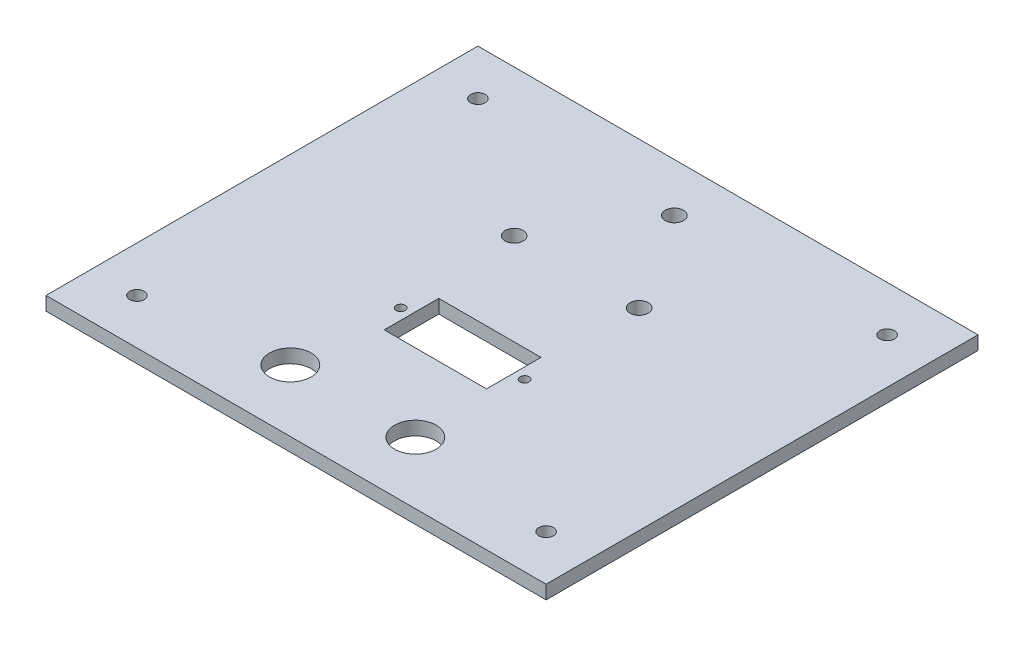
from build123d import *

# Parameters (mm, degrees)
SKETCH1_W           = 110
SKETCH1_H           = 95
SKETCH1_R           = 2
BOSS_EXTRUDE1_DEPTH = 3
SKETCH2_R           = 1.6
CUT_EXTRUDE1_DEPTH  = 3
SKETCH4_R           = 4.575
CUT_EXTRUDE3_DEPTH  = 3
SKETCH5_R           = 1
SKETCH5_W           = 22.5
SKETCH5_H           = 12
CUT_EXTRUDE4_DEPTH  = 10


with BuildPart() as part:
    # Sketch1 → Boss-Extrude1 (new body)
    with BuildSketch(Plane(origin=(0, 0, 0), x_dir=(1, 0, 0), z_dir=(0, 1, 0))):
        Rectangle(SKETCH1_W, SKETCH1_H)
        with Locations((-1.134990048, 36.85560657)):
            Circle(SKETCH1_R, mode=Mode.SUBTRACT)
        with Locations((-14.884990048, 15.35560657)):
            Circle(SKETCH1_R, mode=Mode.SUBTRACT)
        with Locations((12.615009952, 15.35560657)):
            Circle(SKETCH1_R, mode=Mode.SUBTRACT)
    extrude(amount=BOSS_EXTRUDE1_DEPTH)

    # Sketch2 → Cut-Extrude1 (cut)
    with BuildSketch(Plane(origin=(0, 3, 0), x_dir=(1, 0, 0), z_dir=(0, 1, 0))):
        with Locations((-45, 37.5)):
            Circle(SKETCH2_R)
        with Locations((45, 37.5)):
            Circle(SKETCH2_R)
        with Locations((-45, -37.5)):
            Circle(SKETCH2_R)
        with Locations((45, -37.5)):
            Circle(SKETCH2_R)
    extrude(amount=-CUT_EXTRUDE1_DEPTH, mode=Mode.SUBTRACT)

    # Sketch4 → Cut-Extrude3 (cut)
    with BuildSketch(Plane(origin=(0, 3, 0), x_dir=(1, 0, 0), z_dir=(0, 1, 0))):
        with Locations((-14.884990048, -33.869690938)):
            Circle(SKETCH4_R)
        with Locations((12.615009952, -33.869690938)):
            Circle(SKETCH4_R)
    extrude(amount=-CUT_EXTRUDE3_DEPTH, mode=Mode.SUBTRACT)

    # Sketch5 → Cut-Extrude4 (cut)
    with BuildSketch(Plane(origin=(0, 3, 0), x_dir=(1, 0, 0), z_dir=(0, 1, 0))):
        with Locations((-13.625, -10.858715864)):
            Circle(SKETCH5_R)
        with Locations((13.625, -10.858715864)):
            Circle(SKETCH5_R)
        with Locations((0, -10.858715864)):
            Rectangle(SKETCH5_W, SKETCH5_H)
    extrude(amount=-CUT_EXTRUDE4_DEPTH, mode=Mode.SUBTRACT)


solid = part.part
